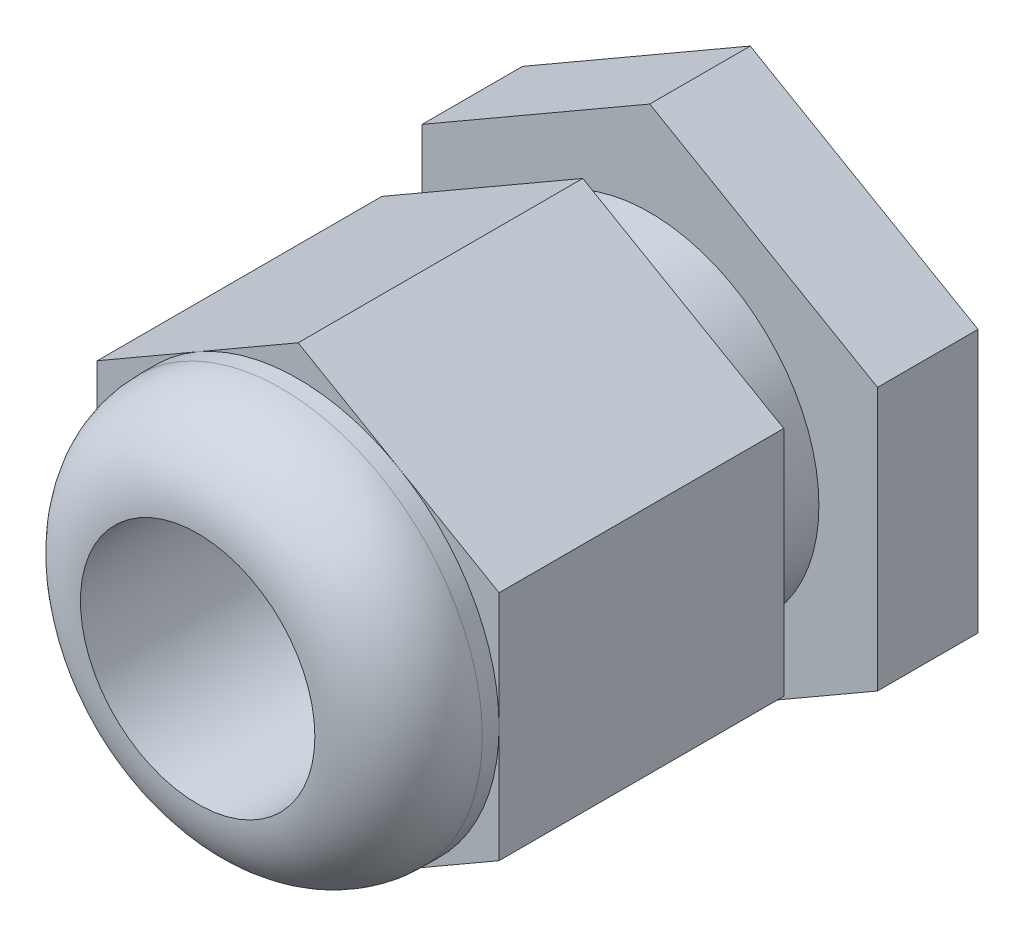
from build123d import *

# Parameters (mm, degrees)
RESSALTO_EXTRUS_O1_DEPTH = 8.5
ESBO_O2_R                = 12
RESSALTO_EXTRUS_O2_DEPTH = 6
FILETE1_R                = 5
ESBO_O3_R                = 10.1
RESSALTO_EXTRUS_O3_DEPTH = 10
RESSALTO_EXTRUS_O4_DEPTH = 6
ESBO_O5_R                = 10.1
RESSALTO_EXTRUS_O5_DEPTH = 1
CORTE_EXTRUS_O1_REACH    = 36
ESBO_O6_R                = 7


with BuildPart() as part:
    # Esboço1 → Ressalto-extrusão1 (new body, symmetric)
    with BuildSketch(Plane.XY):
        Polygon((0, 13.856406461), (-12, 6.92820323), (-12, -6.92820323), (0, -13.856406461), (12, -6.92820323), (12, 6.92820323), align=None)
    extrude(amount=RESSALTO_EXTRUS_O1_DEPTH, both=True)

    # Esboço2 → Ressalto-extrusão2 (add)
    with BuildSketch(Plane.XY.offset(8.5)):
        Circle(ESBO_O2_R)
    extrude(amount=RESSALTO_EXTRUS_O2_DEPTH)

    # Filete1
    filete1_edges = [part.edges().sort_by_distance(p)[0] for p in [
        (-12, 0, 14.5),
    ]]
    fillet(filete1_edges, radius=FILETE1_R)

    # Esboço3 → Ressalto-extrusão3 (add)
    with BuildSketch(Plane(origin=(0, 0, -8.5), x_dir=(-1, 0, 0), z_dir=(0, 0, -1))):
        Circle(ESBO_O3_R)
    extrude(amount=RESSALTO_EXTRUS_O3_DEPTH)

    # Esboço4 → Ressalto-extrusão4 (add)
    with BuildSketch(Plane(origin=(0, 0, -18.5), x_dir=(-1, 0, 0), z_dir=(0, 0, -1))):
        Polygon((0, 15.703927322), (-13.6, 7.851963661), (-13.6, -7.851963661), (0, -15.703927322), (13.6, -7.851963661), (13.6, 7.851963661), align=None)
    extrude(amount=-RESSALTO_EXTRUS_O4_DEPTH)

    # Esboço5 → Ressalto-extrusão5 (add)
    with BuildSketch(Plane(origin=(0, 0, -18.5), x_dir=(-1, 0, 0), z_dir=(0, 0, -1))):
        Circle(ESBO_O5_R)
    extrude(amount=RESSALTO_EXTRUS_O5_DEPTH)

    # Esboço6 → Corte-extrusão1 (cut, up to next)
    with BuildSketch(Plane.XY.offset(14.5), mode=Mode.PRIVATE) as corte_extrus_o1_sk1:
        Circle(ESBO_O6_R)
    corte_extrus_o1_tool1 = extrude(corte_extrus_o1_sk1.sketch, amount=-CORTE_EXTRUS_O1_REACH, mode=Mode.PRIVATE) & part.part
    add(corte_extrus_o1_tool1.solids().sort_by_distance((0, 0, 14.5))[0], mode=Mode.SUBTRACT)


solid = part.part
